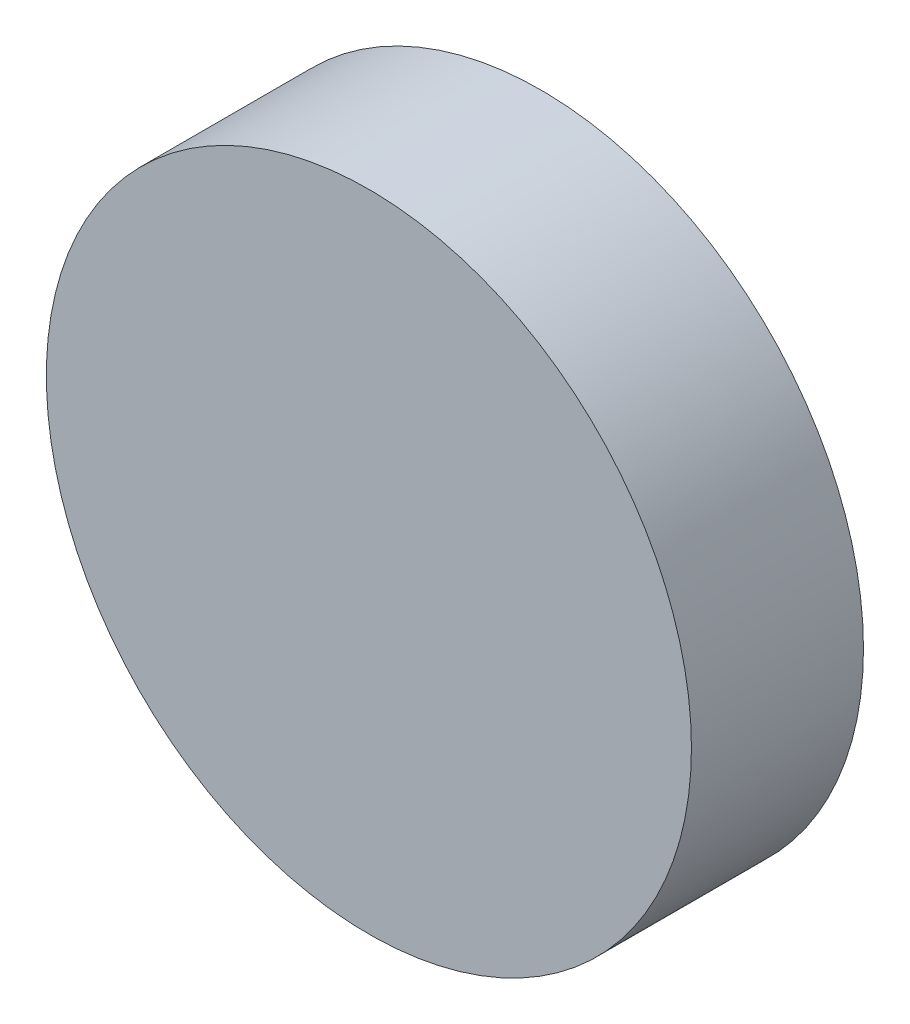
from build123d import *

# Parameters (mm, degrees)
SKETCH1_R           = 4.5
BOSS_EXTRUDE1_DEPTH = 2.4
SKETCH2_R           = 0.5
CUT_EXTRUDE1_DEPTH  = 0.5


with BuildPart() as part:
    # Sketch1 → Boss-Extrude1 (new body)
    with BuildSketch(Plane.XY):
        Circle(SKETCH1_R)
    extrude(amount=BOSS_EXTRUDE1_DEPTH)

    # Sketch2 → Cut-Extrude1 (cut)
    with BuildSketch(Plane(origin=(0, 0, 0), x_dir=(-1, 0, 0), z_dir=(0, 0, -1))):
        with Locations((2, 0.068183801)):
            Circle(SKETCH2_R)
        with Locations((-2, -0.055218249)):
            Circle(SKETCH2_R)
    extrude(amount=-CUT_EXTRUDE1_DEPTH, mode=Mode.SUBTRACT)


solid = part.part
